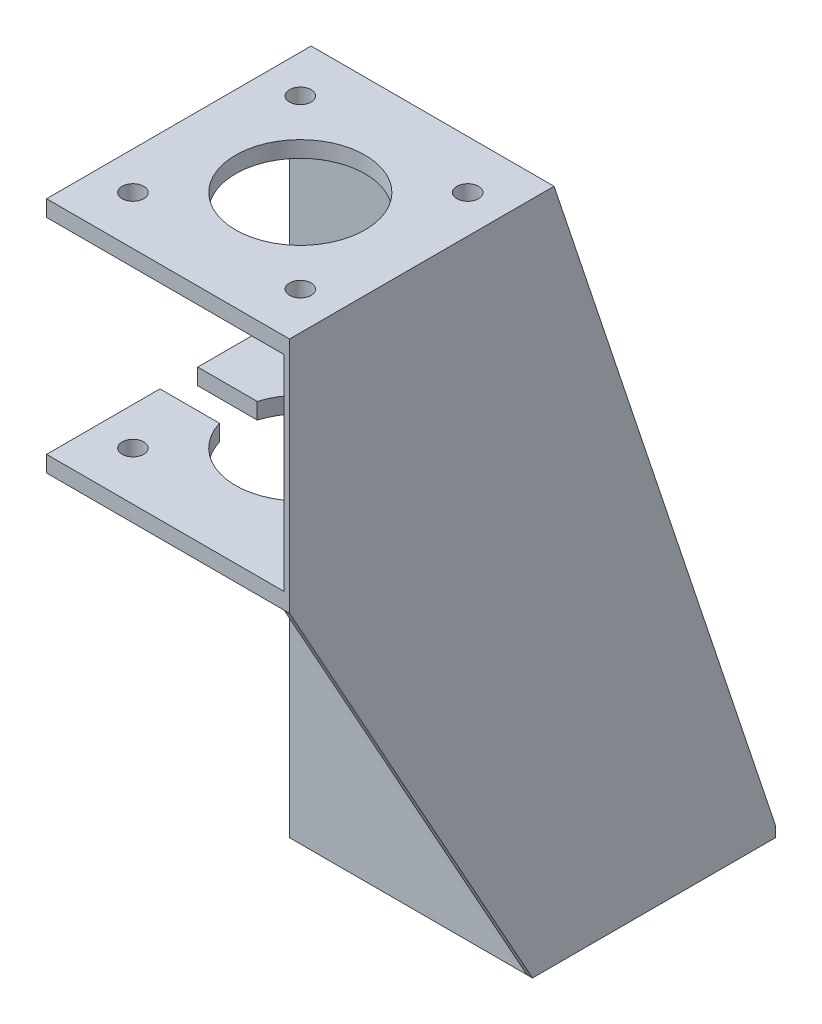
from build123d import *

# Parameters (mm, degrees)
CROQUIS1_W              = 45
CROQUIS1_H              = 45
SALIENTE_EXTRUIR1_DEPTH = 2
CORTAR_EXTRUIR1_DEPTH   = 2
CROQUIS3_W              = 45
CROQUIS3_H              = 4
SALIENTE_EXTRUIR2_DEPTH = 120
CROQUIS4_W              = 45
CROQUIS4_H              = 4
SALIENTE_EXTRUIR3_DEPTH = 3
CROQUIS5_W              = 45
CROQUIS5_H              = 3
SALIENTE_EXTRUIR4_DEPTH = 45
CROQUIS6_R              = 12
CROQUIS6_R_2            = 2
CORTAR_EXTRUIR2_DEPTH   = 3
CROQUIS7_W              = 45
CROQUIS7_H              = 3
SALIENTE_EXTRUIR5_DEPTH = 45
CROQUIS8_R              = 12
CROQUIS8_R_2            = 2
CORTAR_EXTRUIR4_DEPTH   = 44
CROQUIS11_W             = 27.899668072
CROQUIS11_H             = 7
CORTAR_EXTRUIR5_DEPTH   = 45
SALIENTE_EXTRUIR6_DEPTH = 1
SALIENTE_EXTRUIR7_DEPTH = 1
SALIENTE_EXTRUIR8_DEPTH = 1


with BuildPart() as part:
    # Croquis1 → Saliente-Extruir1 (new body)
    with BuildSketch(Plane(origin=(0, 0, 0), x_dir=(1, 0, 0), z_dir=(0, 1, 0))):
        Rectangle(CROQUIS1_W, CROQUIS1_H)
    extrude(amount=SALIENTE_EXTRUIR1_DEPTH)

    # Croquis2 → Cortar-Extruir1 (cut)
    with BuildSketch(Plane(origin=(0, 2, 0), x_dir=(1, 0, 0), z_dir=(0, 1, 0))):
        with BuildLine():
            Line((-18, -14.692077551), (-18, 15.307922449))
            ThreePointArc((-18, 15.307922449), (-15, 18.307922449), (-12, 15.307922449))
            Line((-12, 15.307922449), (-12, -14.692077551))
            ThreePointArc((-12, -14.692077551), (-15, -17.692077551), (-18, -14.692077551))
        make_face()
        with BuildLine():
            Line((18, -14.692077551), (18, 15.307922449))
            ThreePointArc((18, 15.307922449), (15, 18.307922449), (12, 15.307922449))
            Line((12, 15.307922449), (12, -14.692077551))
            ThreePointArc((12, -14.692077551), (15, -17.692077551), (18, -14.692077551))
        make_face()
    extrude(amount=-CORTAR_EXTRUIR1_DEPTH, mode=Mode.SUBTRACT)

    # Croquis3 → Saliente-Extruir2 (add)
    with BuildSketch(Plane(origin=(0, 2, 0), x_dir=(1, 0, 0), z_dir=(0, 1, 0))):
        with Locations((0, -20.5)):
            Rectangle(CROQUIS3_W, CROQUIS3_H)
    extrude(amount=SALIENTE_EXTRUIR2_DEPTH)

    # Croquis4 → Saliente-Extruir3 (add)
    with BuildSketch(Plane(origin=(0, 122, 0), x_dir=(1, 0, 0), z_dir=(0, 1, 0))):
        with Locations((0, -20.5)):
            Rectangle(CROQUIS4_W, CROQUIS4_H)
    extrude(amount=SALIENTE_EXTRUIR3_DEPTH)

    # Croquis5 → Saliente-Extruir4 (add)
    with BuildSketch(Plane.XY.offset(22.5)):
        with Locations((0, 123.5)):
            Rectangle(CROQUIS5_W, CROQUIS5_H)
    extrude(amount=SALIENTE_EXTRUIR4_DEPTH)

    # Croquis6 → Cortar-Extruir2 (cut)
    with BuildSketch(Plane(origin=(0, 125, 0), x_dir=(1, 0, 0), z_dir=(0, 1, 0))):
        with Locations((0, -43)):
            Circle(CROQUIS6_R)
        with Locations((-15.5, -27.5)):
            Circle(CROQUIS6_R_2)
        with Locations((15.5, -27.5)):
            Circle(CROQUIS6_R_2)
        with Locations((15.5, -58.5)):
            Circle(CROQUIS6_R_2)
        with Locations((-15.5, -58.5)):
            Circle(CROQUIS6_R_2)
    extrude(amount=-CORTAR_EXTRUIR2_DEPTH, mode=Mode.SUBTRACT)

    # Croquis7 → Saliente-Extruir5 (add)
    with BuildSketch(Plane.XY.offset(22.5)):
        with Locations((0, 82.5)):
            Rectangle(CROQUIS7_W, CROQUIS7_H)
    extrude(amount=SALIENTE_EXTRUIR5_DEPTH)

    # Croquis8 → Cortar-Extruir4 (cut)
    with BuildSketch(Plane(origin=(0, 125, 0), x_dir=(1, 0, 0), z_dir=(0, 1, 0))):
        with Locations((0, -43)):
            Circle(CROQUIS8_R)
        with Locations((15.5, -58.5)):
            Circle(CROQUIS8_R_2)
        with Locations((15.5, -27.5)):
            Circle(CROQUIS8_R_2)
        with Locations((-15.5, -27.5)):
            Circle(CROQUIS8_R_2)
        with Locations((-15.5, -58.5)):
            Circle(CROQUIS8_R_2)
    extrude(amount=-CORTAR_EXTRUIR4_DEPTH, mode=Mode.SUBTRACT)

    # Croquis11 → Cortar-Extruir5 (cut)
    with BuildSketch(Plane(origin=(0, 84, 0), x_dir=(1, 0, 0), z_dir=(0, 1, 0))):
        with Locations((-22.5, -43)):
            Rectangle(CROQUIS11_W, CROQUIS11_H)
    extrude(amount=-CORTAR_EXTRUIR5_DEPTH, mode=Mode.SUBTRACT)

    # Croquis14 → Saliente-Extruir6 (add)
    with BuildSketch(Plane(origin=(22.5, 0, 0), x_dir=(0, 0, -1), z_dir=(1, 0, 0))):
        Polygon((-67.5, 122), (-67.5, 84), (-18.5, 84), (-18.5, 125), (-67.5, 125), align=None)
    extrude(amount=-SALIENTE_EXTRUIR6_DEPTH)

    # Croquis16 → Saliente-Extruir7 (add)
    with BuildSketch(Plane(origin=(22.5, 0, 0), x_dir=(0, 0, -1), z_dir=(1, 0, 0))):
        Polygon((-18.5, 125), (22.5, 2), (22.5, 0), (-22.5, 0), (-22.5, 125), align=None)
    extrude(amount=-SALIENTE_EXTRUIR7_DEPTH)

    # Croquis17 → Saliente-Extruir8 (add)
    with BuildSketch(Plane(origin=(22.5, 0, 0), x_dir=(0, 0, -1), z_dir=(1, 0, 0))):
        Polygon((-67.5, 81), (-22.5, 0), (-22.5, 84), (-67.5, 84), align=None)
    extrude(amount=-SALIENTE_EXTRUIR8_DEPTH)


solid = part.part
